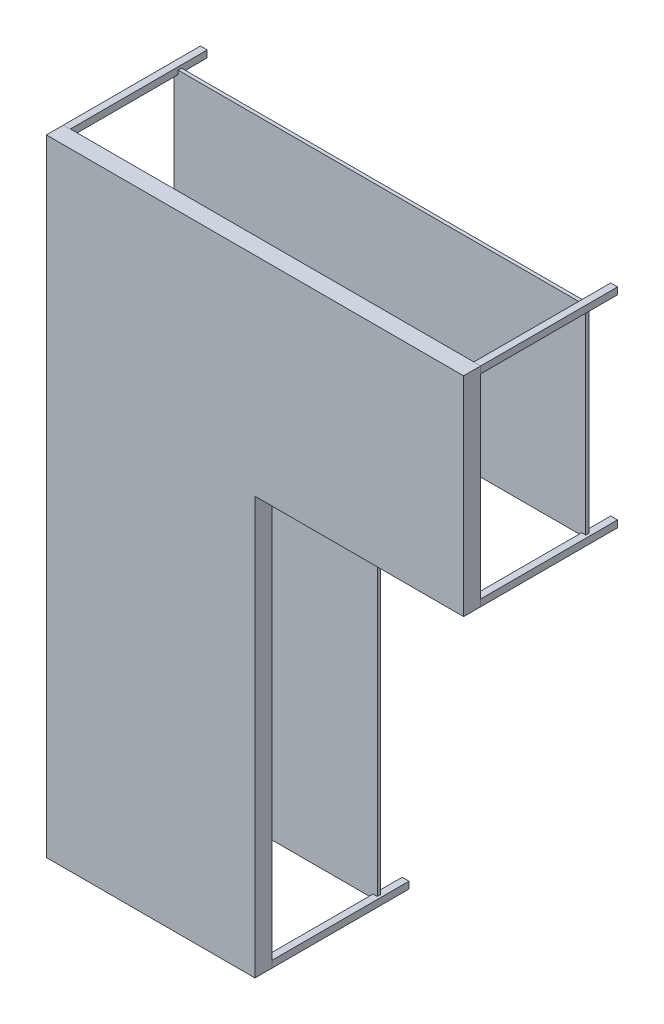
from build123d import *

# Parameters (mm, degrees)
BOSS_EXTRUDE1_DEPTH   = 100
SKETCH4_W             = 40
SKETCH4_H             = 40
BOSS_EXTRUDE2_DEPTH   = 800
BOSS_EXTRUDE2_2_DEPTH = 800
BOSS_EXTRUDE2_3_DEPTH = 800
BOSS_EXTRUDE2_4_DEPTH = 800
BOSS_EXTRUDE2_5_DEPTH = 800
BOSS_EXTRUDE2_6_DEPTH = 800
BOSS_EXTRUDE2_7_DEPTH = 800
SKETCH6_W             = 1187.965611175
SKETCH6_H             = 2434.511231257
BOSS_EXTRUDE3_DEPTH   = 20
SKETCH6_W_2           = 2406.275176363
SKETCH6_H_2           = 1175.992672809
BOSS_EXTRUDE3_2_DEPTH = 20


with BuildPart() as part:
    # Sketch3 → Boss-Extrude1 (new body)
    with BuildSketch(Plane.XY):
        Polygon((2438.4, -1219.2), (2438.4, 0), (0, 0), (0, -3657.6), (1219.2, -3657.6), (1219.2, -1219.2), align=None)
    extrude(amount=BOSS_EXTRUDE1_DEPTH)


with BuildPart() as body_2:
    # Sketch4 → Boss-Extrude2 (new body)
    with BuildSketch(Plane(origin=(0, 0, 0), x_dir=(-1, 0, 0), z_dir=(0, 0, -1))):
        with Locations((-2418.4, -20)):
            Rectangle(SKETCH4_W, SKETCH4_H)
    extrude(amount=BOSS_EXTRUDE2_DEPTH)


with BuildPart() as body_3:
    # Sketch4 → Boss-Extrude2 2 (new body)
    with BuildSketch(Plane(origin=(0, 0, 0), x_dir=(-1, 0, 0), z_dir=(0, 0, -1))):
        with Locations((-20, -3637.6)):
            Rectangle(SKETCH4_W, SKETCH4_H)
    extrude(amount=BOSS_EXTRUDE2_2_DEPTH)


with BuildPart() as body_4:
    # Sketch4 → Boss-Extrude2 3 (new body)
    with BuildSketch(Plane(origin=(0, 0, 0), x_dir=(-1, 0, 0), z_dir=(0, 0, -1))):
        with Locations((-20, -20)):
            Rectangle(SKETCH4_W, SKETCH4_H)
    extrude(amount=BOSS_EXTRUDE2_3_DEPTH)


with BuildPart() as body_5:
    # Sketch4 → Boss-Extrude2 4 (new body)
    with BuildSketch(Plane(origin=(0, 0, 0), x_dir=(-1, 0, 0), z_dir=(0, 0, -1))):
        with Locations((-1199.2, -3637.6)):
            Rectangle(SKETCH4_W, SKETCH4_H)
    extrude(amount=BOSS_EXTRUDE2_4_DEPTH)


with BuildPart() as body_6:
    # Sketch4 → Boss-Extrude2 5 (new body)
    with BuildSketch(Plane(origin=(0, 0, 0), x_dir=(-1, 0, 0), z_dir=(0, 0, -1))):
        with Locations((-1199.2, -1199.2)):
            Rectangle(SKETCH4_W, SKETCH4_H)
    extrude(amount=BOSS_EXTRUDE2_5_DEPTH)


with BuildPart() as body_7:
    # Sketch4 → Boss-Extrude2 6 (new body)
    with BuildSketch(Plane(origin=(0, 0, 0), x_dir=(-1, 0, 0), z_dir=(0, 0, -1))):
        with Locations((-2418.4, -1199.2)):
            Rectangle(SKETCH4_W, SKETCH4_H)
    extrude(amount=BOSS_EXTRUDE2_6_DEPTH)


with BuildPart() as body_8:
    # Sketch4 → Boss-Extrude2 7 (new body)
    with BuildSketch(Plane(origin=(0, 0, 0), x_dir=(-1, 0, 0), z_dir=(0, 0, -1))):
        with Locations((-20, -1199.2)):
            Rectangle(SKETCH4_W, SKETCH4_H)
    extrude(amount=BOSS_EXTRUDE2_7_DEPTH)


with BuildPart() as body_9:
    # Sketch6 → Boss-Extrude3 (new body)
    with BuildSketch(Plane(origin=(0, 0, -650), x_dir=(-1, 0, 0), z_dir=(0, 0, -1))):
        with Locations((-609.9067477, -2422.383402445)):
            Rectangle(SKETCH6_W, SKETCH6_H)
    extrude(amount=-BOSS_EXTRUDE3_DEPTH)


with BuildPart() as body_10:
    # Sketch6 → Boss-Extrude3 2 (new body)
    with BuildSketch(Plane(origin=(0, 0, -650), x_dir=(-1, 0, 0), z_dir=(0, 0, -1))):
        with Locations((-1219.061530294, -605.196403842)):
            Rectangle(SKETCH6_W_2, SKETCH6_H_2)
    extrude(amount=-BOSS_EXTRUDE3_2_DEPTH)


solid = Compound([part.part, body_2.part, body_3.part, body_4.part, body_5.part, body_6.part, body_7.part, body_8.part, body_9.part, body_10.part])
